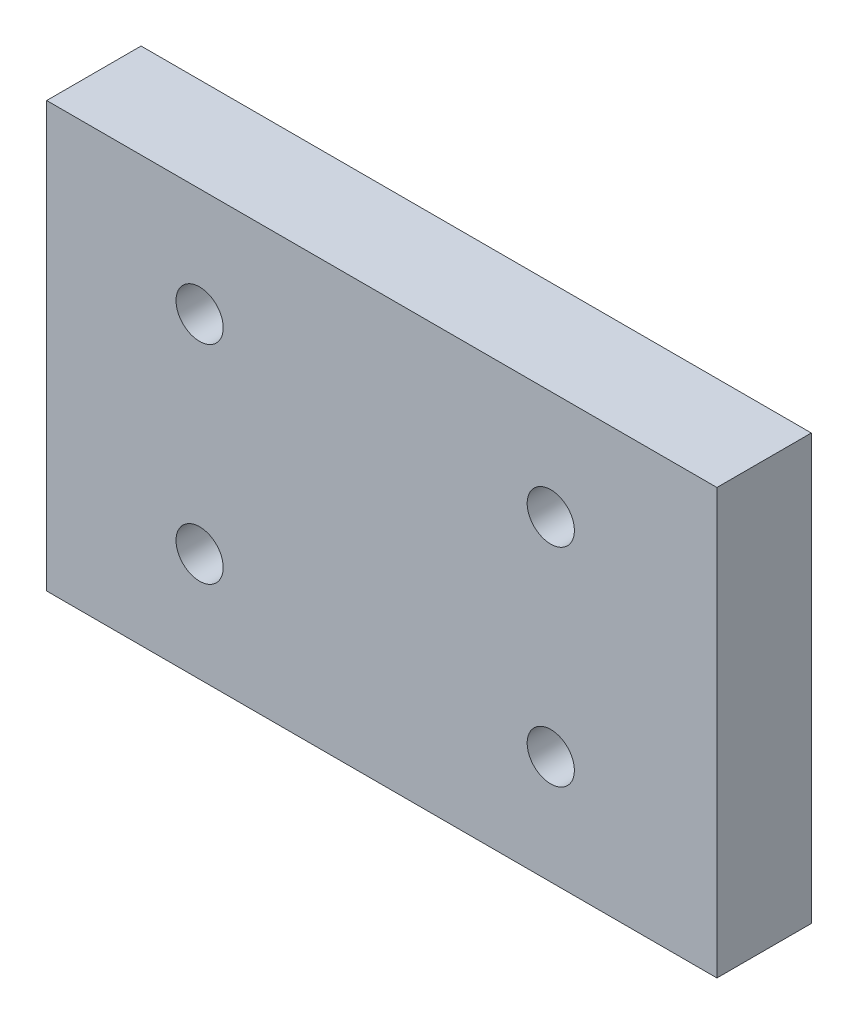
from build123d import *

# Parameters (mm, degrees)
SKETCH1_W           = 71
SKETCH1_H           = 45
SKETCH1_R           = 2.5
BOSS_EXTRUDE1_DEPTH = 10


with BuildPart() as part:
    # Sketch1 → Boss-Extrude1 (new body)
    with BuildSketch(Plane.XY):
        with Locations((25.5, 12.5)):
            Rectangle(SKETCH1_W, SKETCH1_H)
        with Locations((43.4, 1.5)):
            Circle(SKETCH1_R, mode=Mode.SUBTRACT)
        with Locations((6.2, 1.5)):
            Circle(SKETCH1_R, mode=Mode.SUBTRACT)
        with Locations((43.4, 23.5)):
            Circle(SKETCH1_R, mode=Mode.SUBTRACT)
        with Locations((6.2, 23.5)):
            Circle(SKETCH1_R, mode=Mode.SUBTRACT)
    extrude(amount=BOSS_EXTRUDE1_DEPTH)


solid = part.part
